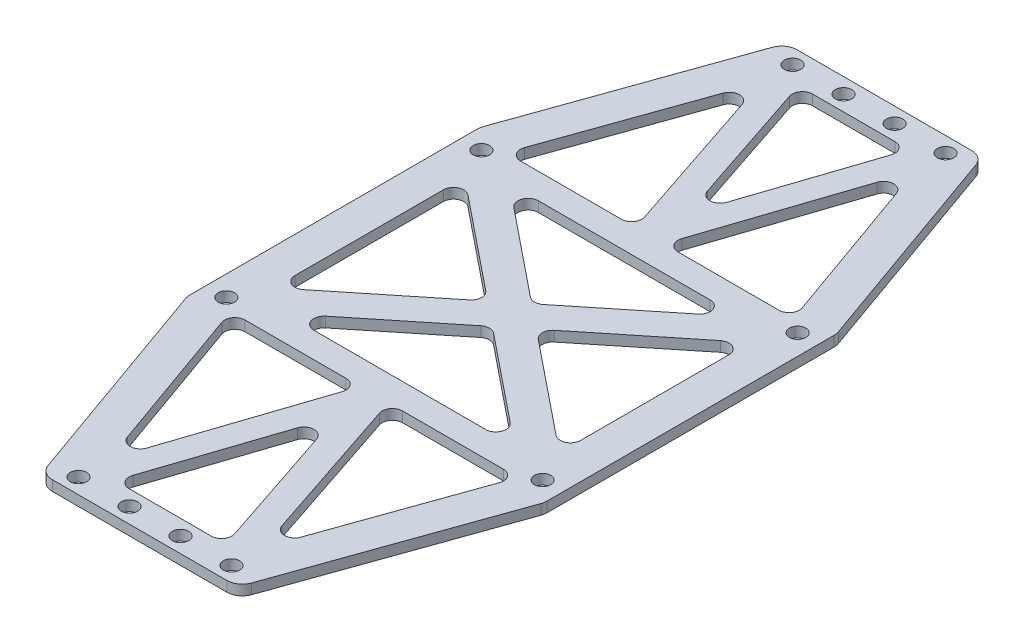
from build123d import *

# Parameters (mm, degrees)
SKETCH_1_R          = 1.6
EXTRUDE_1_DEPTH     = 2
CUT_EXTRUDE_1_DEPTH = 3
FILLET_1_R          = 3


with BuildPart() as part:
    # 草图1 → 凸台-拉伸1 (new body)
    with BuildSketch(Plane(origin=(0, 0, 0), x_dir=(1, 0, 0), z_dir=(0, 1, 0))):
        Polygon((35, -28.67494242), (19.239979527, -73), (-19.239979527, -73), (-35, -28.67494242), (-35, 28.67494242), (-19.239979527, 73), (19.239979527, 73), (35, 28.67494242), align=None)
        with Locations((-31, 25)):
            Circle(SKETCH_1_R, mode=Mode.SUBTRACT)
        with Locations((-31, -25)):
            Circle(SKETCH_1_R, mode=Mode.SUBTRACT)
        with Locations((31, -25)):
            Circle(SKETCH_1_R, mode=Mode.SUBTRACT)
        with Locations((31, 25)):
            Circle(SKETCH_1_R, mode=Mode.SUBTRACT)
        with Locations((-15, 70)):
            Circle(SKETCH_1_R, mode=Mode.SUBTRACT)
        with Locations((-5, 70)):
            Circle(SKETCH_1_R, mode=Mode.SUBTRACT)
        with Locations((5, 70)):
            Circle(SKETCH_1_R, mode=Mode.SUBTRACT)
        with Locations((15, 70)):
            Circle(SKETCH_1_R, mode=Mode.SUBTRACT)
        with Locations((-5, -70)):
            Circle(SKETCH_1_R, mode=Mode.SUBTRACT)
        with Locations((5, -70)):
            Circle(SKETCH_1_R, mode=Mode.SUBTRACT)
        with Locations((15, -70)):
            Circle(SKETCH_1_R, mode=Mode.SUBTRACT)
        with Locations((-15, -70)):
            Circle(SKETCH_1_R, mode=Mode.SUBTRACT)
    extrude(amount=EXTRUDE_1_DEPTH)

    # 草图2 → 切除-拉伸1 (cut, through all)
    with BuildSketch(Plane(origin=(0, 2, 0), x_dir=(1, 0, 0), z_dir=(0, 1, 0))):
        with BuildLine():
            Line((-3.652336951, -29.632455532), (-13.224638858, -58.349361255))
            ThreePointArc((-13.224638858, -58.349361255), (-15.102140845, -59.71680707), (-17.006434835, -58.386925058))
            Line((-17.006434835, -58.386925058), (-27.216890203, -29.670019335))
            ThreePointArc((-27.216890203, -29.670019335), (-26.966480203, -27.846752123), (-25.332460823, -27))
            Line((-25.332460823, -27), (-5.549703547, -27))
            ThreePointArc((-5.549703547, -27), (-3.927219177, -27.830579431), (-3.652336951, -29.632455532))
        make_face()
        with BuildLine():
            Line((-1.897366596, -40.178932769), (-9.960237162, -64.367544468))
            ThreePointArc((-9.960237162, -64.367544468), (-9.685354937, -66.169420569), (-8.062870566, -67))
            Line((-8.062870566, -67), (8.062870566, -67))
            ThreePointArc((8.062870566, -67), (9.685354937, -66.169420569), (9.960237162, -64.367544468))
            Line((9.960237162, -64.367544468), (1.897366596, -40.178932769))
            ThreePointArc((1.897366596, -40.178932769), (0, -38.811388301), (-1.897366596, -40.178932769))
        make_face()
        with BuildLine():
            Line((5.549703547, -27), (25.332460823, -27))
            ThreePointArc((25.332460823, -27), (26.966480203, -27.846752123), (27.216890203, -29.670019335))
            Line((27.216890203, -29.670019335), (17.006434835, -58.386925058))
            ThreePointArc((17.006434835, -58.386925058), (15.102140845, -59.71680707), (13.224638858, -58.349361255))
            Line((13.224638858, -58.349361255), (3.652336951, -29.632455532))
            ThreePointArc((3.652336951, -29.632455532), (3.927219177, -27.830579431), (5.549703547, -27))
        make_face()
        with BuildLine():
            Line((-28, 14.544416854), (-28, -14.544416854))
            ThreePointArc((-28, -14.544416854), (-26.862841293, -16.348718631), (-24.744495098, -16.101242933))
            Line((-24.744495098, -16.101242933), (-6.709418198, -1.556826079))
            ThreePointArc((-6.709418198, -1.556826079), (-5.964923101, 0), (-6.709418198, 1.556826079))
            Line((-6.709418198, 1.556826079), (-24.744495098, 16.101242933))
            ThreePointArc((-24.744495098, 16.101242933), (-26.862841293, 16.348718631), (-28, 14.544416854))
        make_face()
        with BuildLine():
            Line((24.744495098, -16.101242933), (6.709418198, -1.556826079))
            ThreePointArc((6.709418198, -1.556826079), (5.964923101, 0), (6.709418198, 1.556826079))
            Line((6.709418198, 1.556826079), (24.744495098, 16.101242933))
            ThreePointArc((24.744495098, 16.101242933), (26.862841293, 16.348718631), (28, 14.544416854))
            Line((28, 14.544416854), (28, -14.544416854))
            ThreePointArc((28, -14.544416854), (26.862841293, -16.348718631), (24.744495098, -16.101242933))
        make_face()
        with BuildLine():
            Line((-18.090581802, -18.443173921), (-1.255504902, -4.866499002))
            ThreePointArc((-1.255504902, -4.866499002), (0, -4.423325081), (1.255504902, -4.866499002))
            Line((1.255504902, -4.866499002), (18.090581802, -18.443173921))
            ThreePointArc((18.090581802, -18.443173921), (18.721031851, -20.665713092), (16.835076899, -22))
            Line((16.835076899, -22), (0, -22))
            Line((0, -22), (-16.835076899, -22))
            ThreePointArc((-16.835076899, -22), (-18.721031851, -20.665713092), (-18.090581802, -18.443173921))
        make_face()
        with BuildLine():
            Line((-16.835076899, 22), (0, 22))
            Line((0, 22), (16.835076899, 22))
            ThreePointArc((16.835076899, 22), (18.721031851, 20.665713092), (18.090581802, 18.443173921))
            Line((18.090581802, 18.443173921), (1.255504902, 4.866499002))
            ThreePointArc((1.255504902, 4.866499002), (0, 4.423325081), (-1.255504902, 4.866499002))
            Line((-1.255504902, 4.866499002), (-18.090581802, 18.443173921))
            ThreePointArc((-18.090581802, 18.443173921), (-18.721031851, 20.665713092), (-16.835076899, 22))
        make_face()
        with BuildLine():
            Line((9.960237162, 64.367544468), (1.897366596, 40.178932769))
            ThreePointArc((1.897366596, 40.178932769), (0, 38.811388301), (-1.897366596, 40.178932769))
            Line((-1.897366596, 40.178932769), (-9.960237162, 64.367544468))
            ThreePointArc((-9.960237162, 64.367544468), (-9.685354937, 66.169420569), (-8.062870566, 67))
            Line((-8.062870566, 67), (8.062870566, 67))
            ThreePointArc((8.062870566, 67), (9.685354937, 66.169420569), (9.960237162, 64.367544468))
        make_face()
        with BuildLine():
            Line((13.224638858, 58.349361255), (3.652336951, 29.632455532))
            ThreePointArc((3.652336951, 29.632455532), (3.927219177, 27.830579431), (5.549703547, 27))
            Line((5.549703547, 27), (25.332460823, 27))
            ThreePointArc((25.332460823, 27), (26.966480203, 27.846752123), (27.216890203, 29.670019335))
            Line((27.216890203, 29.670019335), (17.006434835, 58.386925058))
            ThreePointArc((17.006434835, 58.386925058), (15.102140845, 59.71680707), (13.224638858, 58.349361255))
        make_face()
        with BuildLine():
            Line((-25.332460823, 27), (-5.549703547, 27))
            ThreePointArc((-5.549703547, 27), (-3.927219177, 27.830579431), (-3.652336951, 29.632455532))
            Line((-3.652336951, 29.632455532), (-13.224638858, 58.349361255))
            ThreePointArc((-13.224638858, 58.349361255), (-15.102140845, 59.71680707), (-17.006434835, 58.386925058))
            Line((-17.006434835, 58.386925058), (-27.216890203, 29.670019335))
            ThreePointArc((-27.216890203, 29.670019335), (-26.966480203, 27.846752123), (-25.332460823, 27))
        make_face()
    extrude(amount=-CUT_EXTRUDE_1_DEPTH, mode=Mode.SUBTRACT)

    # 圆角1
    fillet_1_edges = [part.edges().sort_by_distance(p)[0] for p in [
        (35, 1, 28.67494242),
        (19.239979527, 1, 73),
        (-19.239979527, 1, 73),
        (-35, 1, 28.67494242),
        (-35, 1, -28.67494242),
        (-19.239979527, 1, -73),
        (19.239979527, 1, -73),
        (35, 1, -28.67494242),
    ]]
    fillet(fillet_1_edges, radius=FILLET_1_R)


solid = part.part
